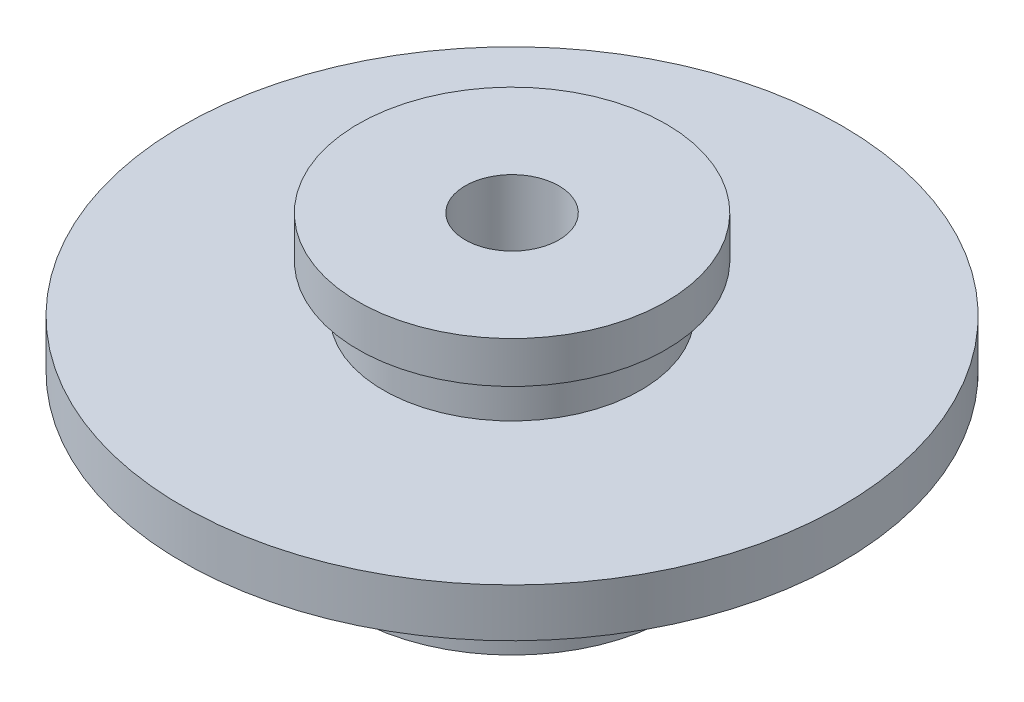
from build123d import *


with BuildPart() as part:
    # Эскиз1 → Повернуть1 (revolve)
    with BuildSketch(Plane.XY):
        Polygon((2.929628343, 0), (2.929628343, 19.870594608), (9.62481701, 19.870594608), (9.62481701, 17.277236909), (8.048190406, 17.277236909), (8.048190406, 14.29424259), (20.600667032, 14.29424259), (20.600667032, 11.272656629), (10, 11.272656629), (10, 3), (5, 2), (5, 0), align=None)
    revolve(axis=Axis((0, -11.441390283, 0), (0, 1, 0)))


solid = part.part
